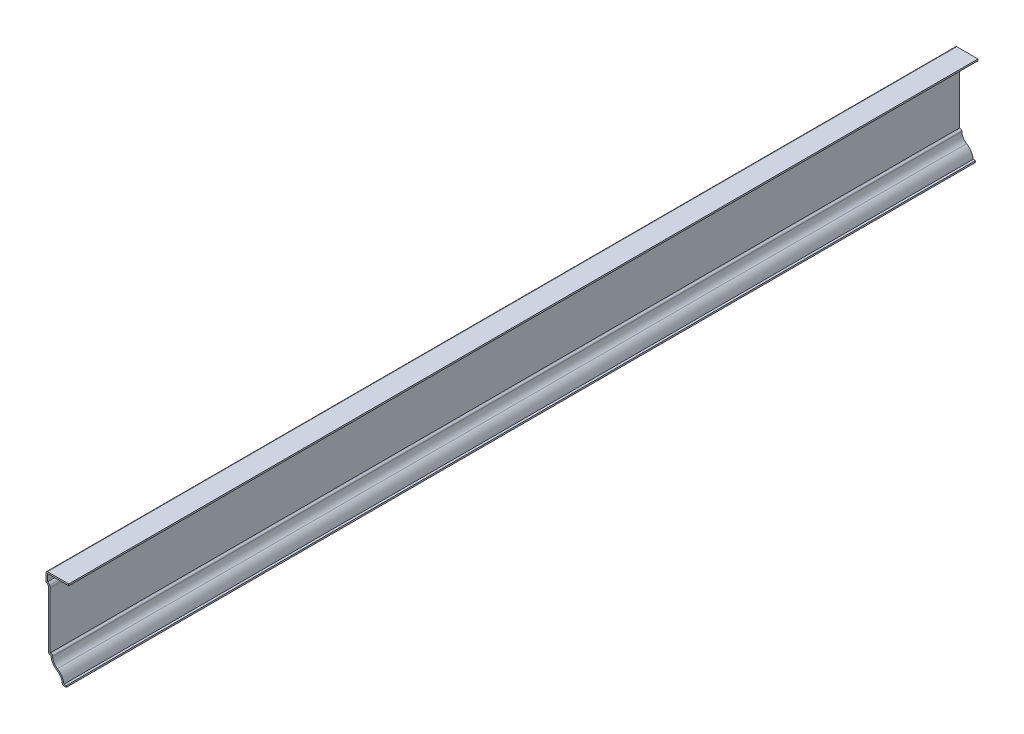
from build123d import *

# Parameters (mm, degrees)
EXTRUDE_THIN1_DEPTH = 571.5
FILLET1_R           = 1.016


with BuildPart() as part:
    # Sketch1 → Extrude-Thin1 (new body)
    with BuildSketch(Plane.XY):
        with BuildLine():
            Line((0, 0), (-2.38125, 0))
            ThreePointArc((-2.38125, 0), (-3.372303364, 3.783352795), (-6.090912463, 6.59495549))
            ThreePointArc((-6.090912463, 6.59495549), (-8.607567743, 9.197696269), (-9.525, 12.7))
            Line((-9.525, 12.7), (-11.1125, 12.7))
            Line((-11.1125, 12.7), (-11.1125, 49.2125))
            ThreePointArc((-11.1125, 49.2125), (-11.577467985, 50.335032015), (-12.7, 50.8))
            Line((-12.7, 50.8), (-12.7, 57.15))
            Line((-12.7, 57.15), (1.5875, 57.15))
            Line((1.5875, 57.15), (1.5875, 56.134))
            Line((1.5875, 56.134), (-11.684, 56.134))
            Line((-11.684, 56.134), (-11.684, 51.609572433))
            ThreePointArc((-11.684, 51.609572433), (-10.529358591, 50.650042391), (-10.0965, 49.2125))
            Line((-10.0965, 49.2125), (-10.0965, 13.716))
            Line((-10.0965, 13.716), (-8.424185054, 13.716))
            ThreePointArc((-8.424185054, 13.716), (-7.953453255, 10.150515553), (-5.563316024, 7.463228487))
            ThreePointArc((-5.563316024, 7.463228487), (-2.749191769, 4.717697591), (-1.424552135, 1.016))
            Line((-1.424552135, 1.016), (0, 1.016))
            Line((0, 1.016), (0, 0))
        make_face()
    extrude(amount=-EXTRUDE_THIN1_DEPTH)

    # Fillet1
    fillet1_edges = [part.edges().sort_by_distance(p)[0] for p in [
        (-8.424185054, 13.716, -285.75),
        (-2.38125, 0, -285.75),
        (-11.1125, 12.7, -285.75),
        (-12.7, 50.8, -285.75),
        (-12.7, 57.15, -285.75),
    ]]
    fillet(fillet1_edges, radius=FILLET1_R)


solid = part.part
